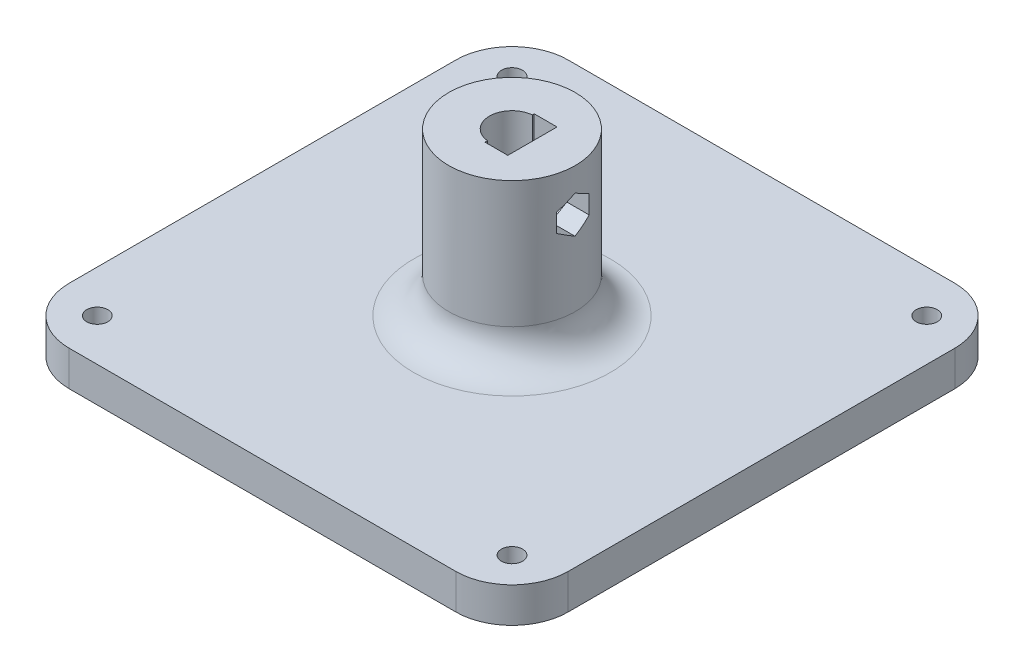
from build123d import *

# Parameters (mm, degrees)
SKETCH1_W               = 71
SKETCH1_H               = 71
BOSS_EXTRUDE1_DEPTH     = 5
SKETCH2_R               = 9
BOSS_EXTRUDE2_DEPTH     = 23
FILLET1_R               = 5
CUT_EXTRUDE1_DEPTH      = 46
FILLET2_R               = 8
SKETCH4_R               = 1.5
CUT_EXTRUDE2_DEPTH      = 6
CUT_EXTRUDE3_DEPTH      = 10
CUT_EXTRUDE4_DEPTH      = 2.5
CUT_EXTRUDE4_DEPTH_BACK = 3.35
FILLET3_R               = 0.5
CUT_EXTRUDE9_DEPTH      = 30.95
SKETCH11_W              = 3.248200577
SKETCH11_H              = 7
CUT_EXTRUDE10_DEPTH     = 5


with BuildPart() as part:
    # Sketch1 → Boss-Extrude1 (new body)
    with BuildSketch(Plane(origin=(0, 0, 0), x_dir=(1, 0, 0), z_dir=(0, 1, 0))):
        with Locations((35.5, 35.5)):
            Rectangle(SKETCH1_W, SKETCH1_H)
    extrude(amount=BOSS_EXTRUDE1_DEPTH)

    # Sketch2 → Boss-Extrude2 (add)
    with BuildSketch(Plane(origin=(0, 5, 0), x_dir=(1, 0, 0), z_dir=(0, 1, 0))):
        with Locations((35.5, 35.5)):
            Circle(SKETCH2_R)
    extrude(amount=BOSS_EXTRUDE2_DEPTH)

    # Fillet1
    fillet1_edges = [part.edges().sort_by_distance(p)[0] for p in [
        (26.5, 5, -35.5),
    ]]
    fillet(fillet1_edges, radius=FILLET1_R)

    # Sketch3 → Cut-Extrude1 (cut)
    with BuildSketch(Plane(origin=(0, 28, 0), x_dir=(1, 0, 0), z_dir=(0, 1, 0))):
        with BuildLine():
            Line((37.7, 33.176209992), (37.7, 37.823790008))
            ThreePointArc((37.7, 37.823790008), (32.3, 35.5), (37.7, 33.176209992))
        make_face()
    extrude(amount=-CUT_EXTRUDE1_DEPTH, mode=Mode.SUBTRACT)

    # Fillet2
    fillet2_edges = [part.edges().sort_by_distance(p)[0] for p in [
        (0, 2.5, -71),
        (71, 2.5, -71),
        (71, 2.5, 0),
        (0, 2.5, 0),
    ]]
    fillet(fillet2_edges, radius=FILLET2_R)

    # Sketch4 → Cut-Extrude2 (cut, through all)
    with BuildSketch(Plane(origin=(0, 5, 0), x_dir=(1, 0, 0), z_dir=(0, 1, 0))):
        with Locations((65, 65)):
            Circle(SKETCH4_R)
        with Locations((65, 6)):
            Circle(SKETCH4_R)
        with Locations((6, 6)):
            Circle(SKETCH4_R)
        with Locations((6, 65)):
            Circle(SKETCH4_R)
    extrude(amount=-CUT_EXTRUDE2_DEPTH, mode=Mode.SUBTRACT)

    # Sketch5 → Cut-Extrude3 (cut)
    with BuildSketch(Plane(origin=(0, 0, 0), x_dir=(-1, 0, 0), z_dir=(0, -1, 0))):
        Polygon((-43.813843876, 35.5), (-39.656921938, 28.3), (-31.343078062, 28.3), (-27.186156124, 35.5), (-31.343078062, 42.7), (-39.656921938, 42.7), align=None)
    extrude(amount=-CUT_EXTRUDE3_DEPTH, mode=Mode.SUBTRACT)

    # Sketch6 → Cut-Extrude4 (cut, two sides)
    with BuildSketch(Plane.ZY.offset(-37.7)) as cut_extrude4_sk:
        Polygon((-35.456209992, 26.041451884), (-38.956209992, 24.020725942), (-38.956209992, 19.979274058), (-35.456209992, 17.958548116), (-31.956209992, 19.979274058), (-31.956209992, 24.020725942), align=None)
    extrude(amount=CUT_EXTRUDE4_DEPTH, mode=Mode.SUBTRACT)
    extrude(cut_extrude4_sk.sketch, amount=-CUT_EXTRUDE4_DEPTH_BACK, mode=Mode.SUBTRACT)

    # Fillet3
    fillet3_edges = [part.edges().sort_by_distance(p)[0] for p in [
        (41.05, 25.031088913, -33.706209992),
        (41.05, 25.031088913, -37.206209992),
        (41.05, 22, -38.956209992),
        (41.05, 18.968911087, -37.206209992),
        (41.05, 18.968911087, -33.706209992),
        (41.05, 22, -31.956209992),
    ]]
    fillet(fillet3_edges, radius=FILLET3_R)

    # Sketch10 → Cut-Extrude9 (cut, through all)
    with BuildSketch(Plane.ZY.offset(-41.05)):
        Polygon((-35.456209992, 24.629291376), (-37.756209992, 23.301385757), (-37.756209992, 20.645574519), (-35.456209992, 19.3176689), (-33.156209992, 20.645574519), (-33.156209992, 23.301385757), align=None)
    extrude(amount=-CUT_EXTRUDE9_DEPTH, mode=Mode.SUBTRACT)

    # Sketch11 → Cut-Extrude10 (cut)
    with BuildSketch(Plane(origin=(0, 28, 0), x_dir=(1, 0, 0), z_dir=(0, 1, 0))):
        with Locations((36.824100289, 35.456209992)):
            Rectangle(SKETCH11_W, SKETCH11_H)
    extrude(amount=-CUT_EXTRUDE10_DEPTH, mode=Mode.SUBTRACT)


solid = part.part
